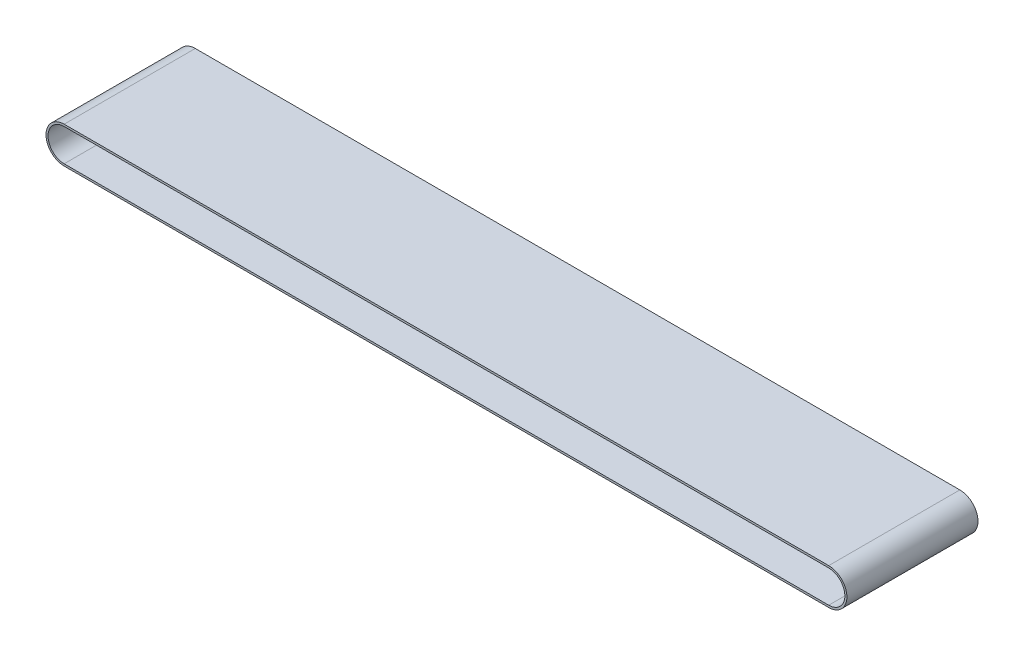
from build123d import *

# Parameters (mm, degrees)
SALIENTE_EXTRUIR1_DEPTH = 130


with BuildPart() as part:
    # Croquis1 → Saliente-Extruir1 (new body)
    with BuildSketch(Plane.XY):
        with BuildLine():
            Line((0, 2), (758, 2))
            ThreePointArc((758, 2), (776, -16), (758, -34))
            Line((758, -34), (0, -34))
            ThreePointArc((0, -34), (-18, -16), (0, 2))
        make_face()
        with BuildLine():
            Line((0, 0), (758, 0))
            ThreePointArc((758, 0), (774, -16), (758, -32))
            Line((758, -32), (0, -32))
            ThreePointArc((0, -32), (-16, -16), (0, 0))
        make_face(mode=Mode.SUBTRACT)
    extrude(amount=SALIENTE_EXTRUIR1_DEPTH)


solid = part.part
